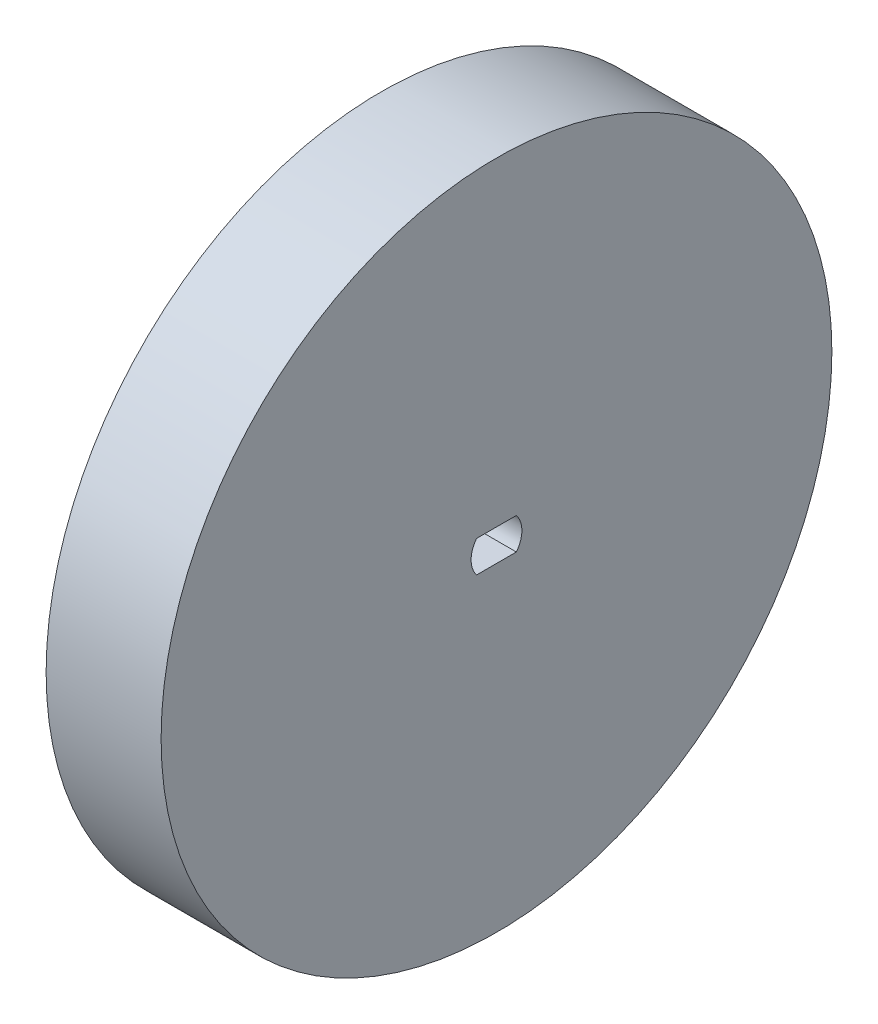
from build123d import *

# Parameters (mm, degrees)
SKETCH1_R           = 35
BOSS_EXTRUDE1_DEPTH = 12


with BuildPart() as part:
    # Sketch1 → Boss-Extrude1 (new body)
    with BuildSketch(Plane(origin=(0, 0, 0), x_dir=(0, 0, -1), z_dir=(1, 0, 0))):
        Circle(SKETCH1_R)
        with BuildLine():
            Line((-2.073644135, 1.65), (2.073644135, 1.65))
            ThreePointArc((2.073644135, 1.65), (2.65, 0), (2.073644135, -1.65))
            Line((2.073644135, -1.65), (-2.073644135, -1.65))
            ThreePointArc((-2.073644135, -1.65), (-2.65, 0), (-2.073644135, 1.65))
        make_face(mode=Mode.SUBTRACT)
    extrude(amount=-BOSS_EXTRUDE1_DEPTH)


solid = part.part
